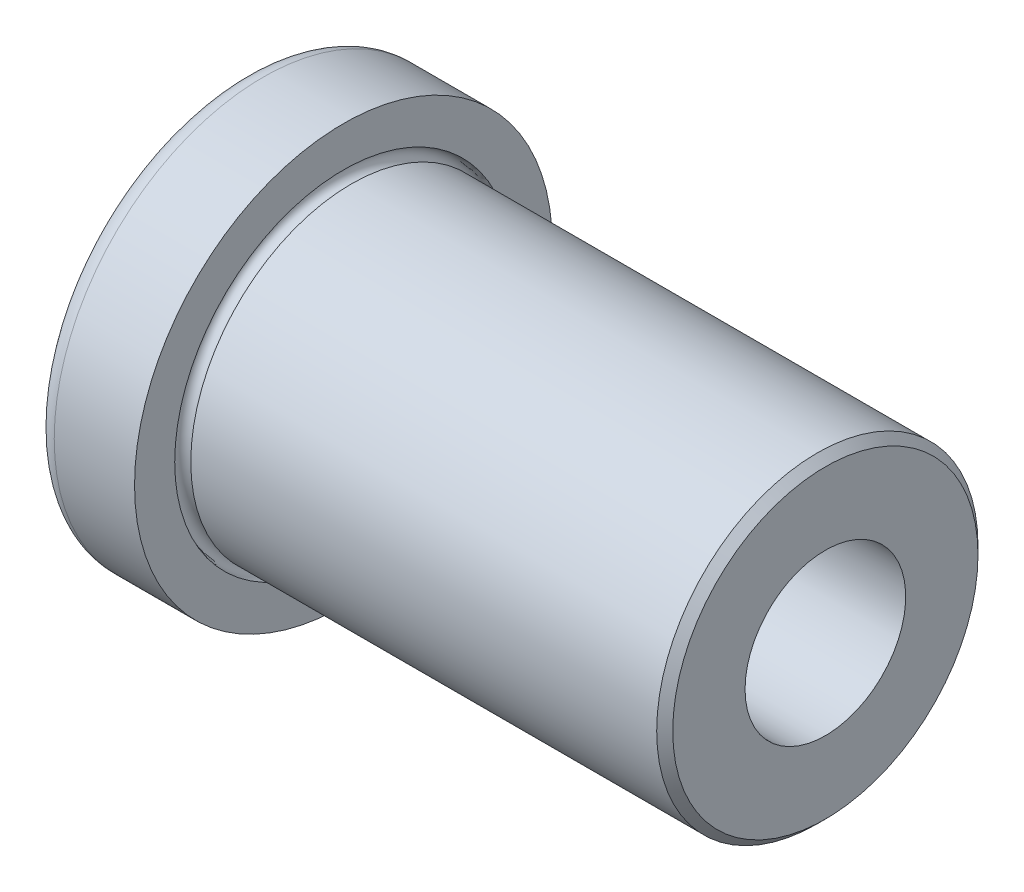
from build123d import *


with BuildPart() as part:
    # Sketch1 → BaseBody (revolve)
    with BuildSketch(Plane.XY):
        with BuildLine():
            Line((0, 3.9624), (0, 7.4676))
            ThreePointArc((0, 7.4676), (0.23062412, 8.02437588), (0.7874, 8.255))
            Line((0.7874, 8.255), (3.9624, 8.255))
            Line((3.9624, 8.255), (3.9624, 6.6675))
            ThreePointArc((3.9624, 6.6675), (3.737893597, 6.125493597), (4.2799, 6.35))
            Line((4.2799, 6.35), (22.6949, 6.35))
            Line((22.6949, 6.35), (23.0124, 6.0325))
            Line((23.0124, 6.0325), (23.0124, 3.175))
            Line((23.0124, 3.175), (0.7874, 3.175))
            ThreePointArc((0.7874, 3.175), (0.23062412, 3.40562412), (0, 3.9624))
        make_face()
    revolve(axis=Axis((0, 0, 0), (1, 0, 0)))


solid = part.part
